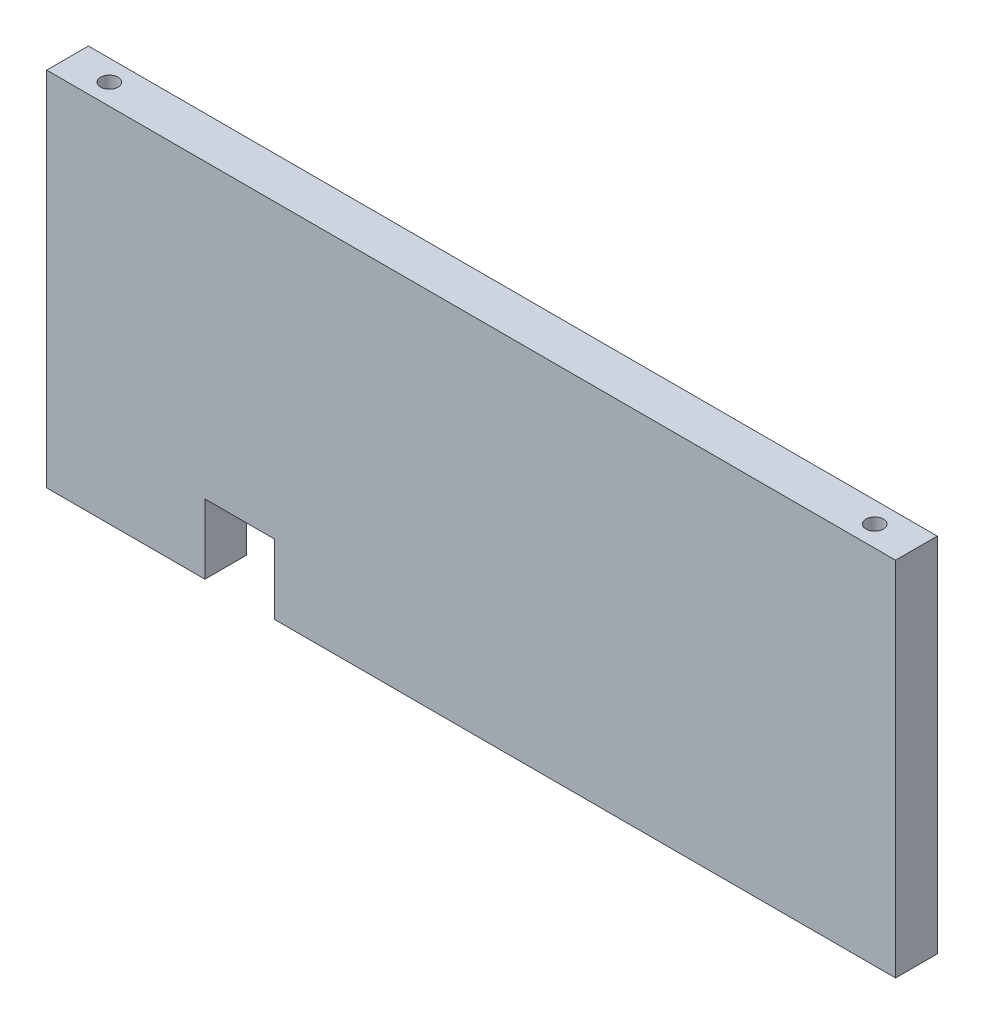
from build123d import *

# Parameters (mm, degrees)
SKETCH1_W           = 122
SKETCH1_H           = 52
BOSS_EXTRUDE1_DEPTH = 6
SKETCH2_R           = 1.25
CUT_EXTRUDE1_DEPTH  = 53
SKETCH3_W           = 10
SKETCH3_H           = 10
CUT_EXTRUDE2_DEPTH  = 10


with BuildPart() as part:
    # Sketch1 → Boss-Extrude1 (new body)
    with BuildSketch(Plane.XY):
        with Locations((5.22260274, 1.88869863)):
            Rectangle(SKETCH1_W, SKETCH1_H)
    extrude(amount=-BOSS_EXTRUDE1_DEPTH)

    # Sketch2 → Cut-Extrude1 (cut, through all)
    with BuildSketch(Plane(origin=(0, 27.88869863, 0), x_dir=(1, 0, 0), z_dir=(0, 1, 0))):
        with Locations((-49.77739726, 3)):
            Circle(SKETCH2_R)
        with Locations((60.22260274, 3)):
            Circle(SKETCH2_R)
    extrude(amount=-CUT_EXTRUDE1_DEPTH, mode=Mode.SUBTRACT)

    # Sketch3 → Cut-Extrude2 (cut)
    with BuildSketch(Plane(origin=(0, 0, -6), x_dir=(-1, 0, 0), z_dir=(0, 0, -1))):
        with Locations((28.036600011, -19.11130137)):
            Rectangle(SKETCH3_W, SKETCH3_H)
    extrude(amount=-CUT_EXTRUDE2_DEPTH, mode=Mode.SUBTRACT)


solid = part.part
